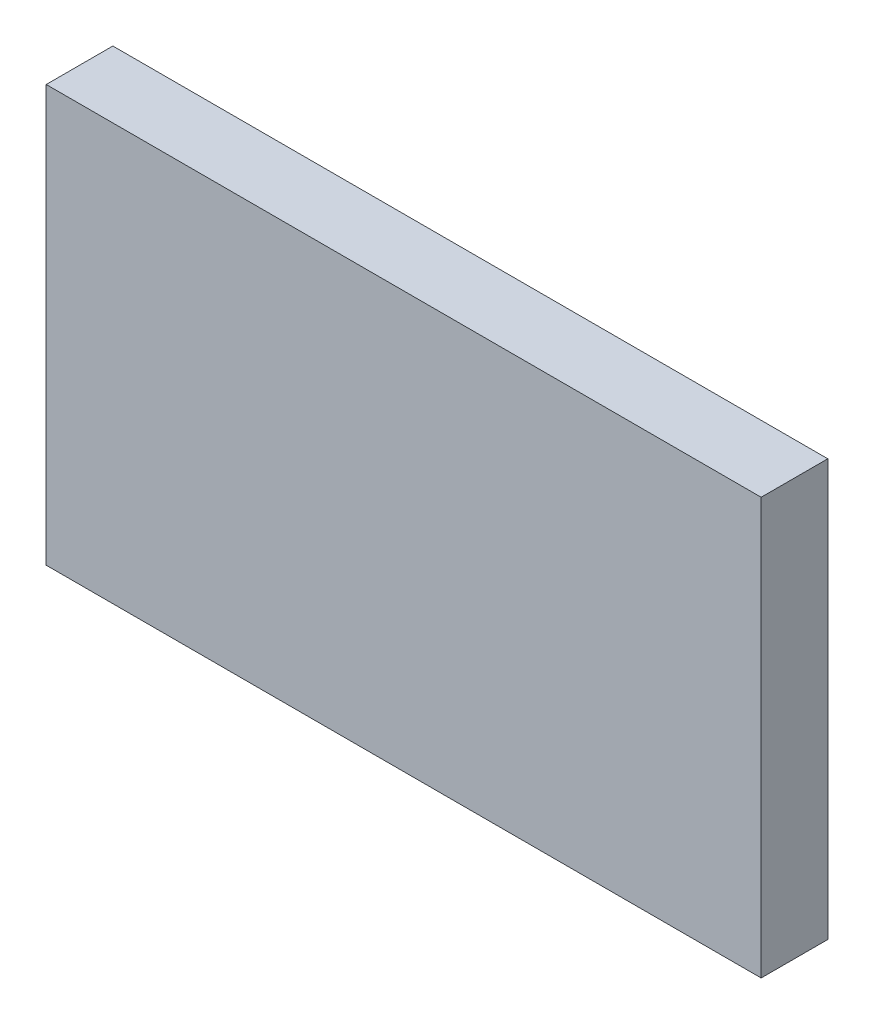
from build123d import *

# Parameters (mm, degrees)
SKETCH_1_W      = 107.279503106
SKETCH_1_H      = 62.474534162
EXTRUDE_1_DEPTH = 10


with BuildPart() as part:
    # 草图1 → 凸台-拉伸1 (new body)
    with BuildSketch(Plane.XY):
        Rectangle(SKETCH_1_W, SKETCH_1_H)
    extrude(amount=EXTRUDE_1_DEPTH)


solid = part.part
